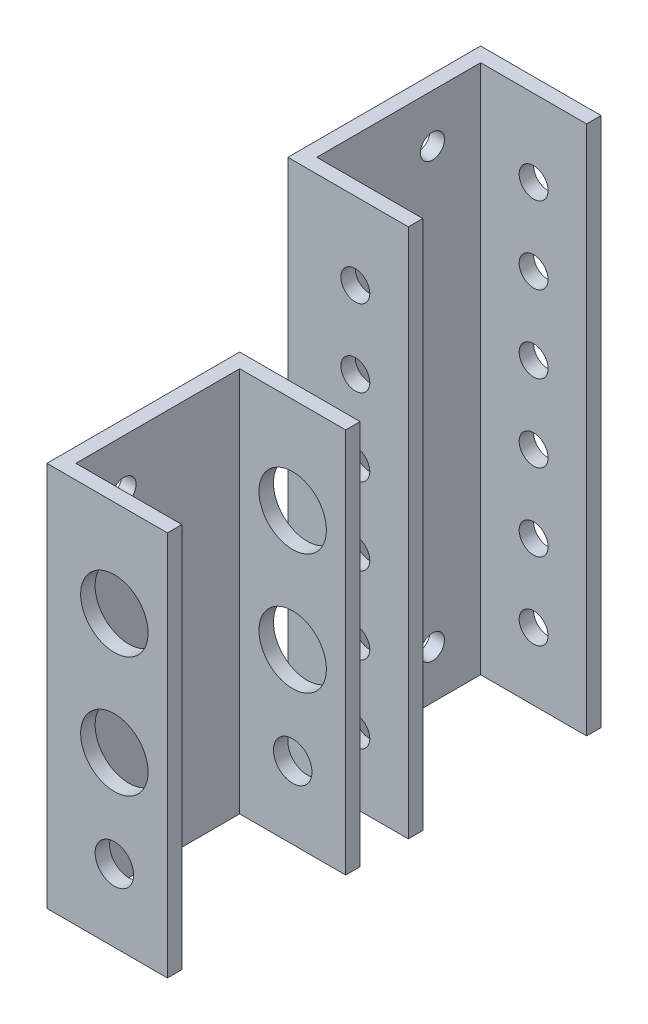
from build123d import *

# Parameters (mm, degrees)
EXTRUDE_2_DEPTH     = 80
EXTRUDE_3_DEPTH     = 110
SKETCH_6_R          = 7
SKETCH_6_R_2        = 4
CUT_EXTRUDE_2_DEPTH = 40
SKETCH_7_R          = 3
CUT_EXTRUDE_3_DEPTH = 40
SKETCH_8_R          = 2.5
CUT_EXTRUDE_4_DEPTH = 40


with BuildPart() as part:
    # 스케치1 → 보스-돌출2 (new body)
    with BuildSketch(Plane(origin=(0, 0, 0), x_dir=(1, 0, 0), z_dir=(0, 1, 0))):
        Polygon((0, 0), (25, 0), (25, 3), (3, 3), (3, 37), (25, 37), (25, 40), (0, 40), align=None)
    extrude(amount=EXTRUDE_2_DEPTH)

    # 스케치6 → 컷-돌출2 (cut)
    with BuildSketch(Plane.XY):
        with Locations((14, 60)):
            Circle(SKETCH_6_R)
        with Locations((14, 35)):
            Circle(SKETCH_6_R)
        with Locations((14, 15)):
            Circle(SKETCH_6_R_2)
    extrude(amount=-CUT_EXTRUDE_2_DEPTH, mode=Mode.SUBTRACT)


with BuildPart() as body_2:
    # 스케치1<4> → 보스-돌출3 (new body)
    with BuildSketch(Plane(origin=(0, 0, 0), x_dir=(1, 0, 0), z_dir=(0, 1, 0))):
        Polygon((25, 90), (25, 87), (3, 87), (3, 53), (25, 53), (25, 50), (0, 50), (0, 90), align=None)
    extrude(amount=EXTRUDE_3_DEPTH)

    # 스케치7 → 컷-돌출3 (cut)
    with BuildSketch(Plane(origin=(0, 0, -90), x_dir=(-1, 0, 0), z_dir=(0, 0, -1))):
        with Locations((-14, 94)):
            Circle(SKETCH_7_R)
        with Locations((-14, 78)):
            Circle(SKETCH_7_R)
        with Locations((-14, 62)):
            Circle(SKETCH_7_R)
        with Locations((-14, 46)):
            Circle(SKETCH_7_R)
        with Locations((-14, 30)):
            Circle(SKETCH_7_R)
        with Locations((-14, 14)):
            Circle(SKETCH_7_R)
    extrude(amount=-CUT_EXTRUDE_3_DEPTH, mode=Mode.SUBTRACT)


with BuildPart() as cut_extrude_4_tool:
    # 스케치8 → 컷-돌출4 (new body)
    with BuildSketch(Plane(origin=(3, 0, 0), x_dir=(0, 0, -1), z_dir=(1, 0, 0))):
        with Locations((77, 100)):
            Circle(SKETCH_8_R)
        with Locations((77, 10)):
            Circle(SKETCH_8_R)
        with Locations((13, 10)):
            Circle(SKETCH_8_R)
        with Locations((13, 70)):
            Circle(SKETCH_8_R)
    extrude(amount=-CUT_EXTRUDE_4_DEPTH)


with BuildPart() as part_1:
    add(part.part)

    # 컷-돌출4: cut by cut_extrude_4_tool
    add(cut_extrude_4_tool.part, mode=Mode.SUBTRACT)


with BuildPart() as body_2_1:
    add(body_2.part)

    # 컷-돌출4: cut by cut_extrude_4_tool
    add(cut_extrude_4_tool.part, mode=Mode.SUBTRACT)


solid = Compound([part_1.part, body_2_1.part])
